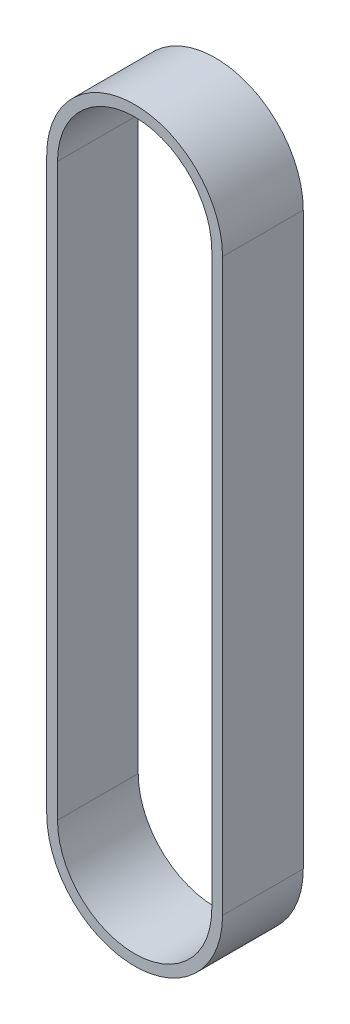
from build123d import *

# Parameters (mm, degrees)
EXTRUDE_1_DEPTH = 7.5


with BuildPart() as part:
    # 草图1 → 拉伸-薄壁1 (new body, symmetric)
    with BuildSketch(Plane.XY):
        with BuildLine():
            Line((16.33, 53), (16.33, -53))
            ThreePointArc((16.33, -53), (0, -69.33), (-16.33, -53))
            Line((-16.33, -53), (-16.33, 53))
            ThreePointArc((-16.33, 53), (0, 69.33), (16.33, 53))
        make_face()
        with BuildLine():
            Line((14.33, 53), (14.33, -53))
            ThreePointArc((14.33, -53), (0, -67.33), (-14.33, -53))
            Line((-14.33, -53), (-14.33, 53))
            ThreePointArc((-14.33, 53), (0, 67.33), (14.33, 53))
        make_face(mode=Mode.SUBTRACT)
    extrude(amount=EXTRUDE_1_DEPTH, both=True)


solid = part.part
